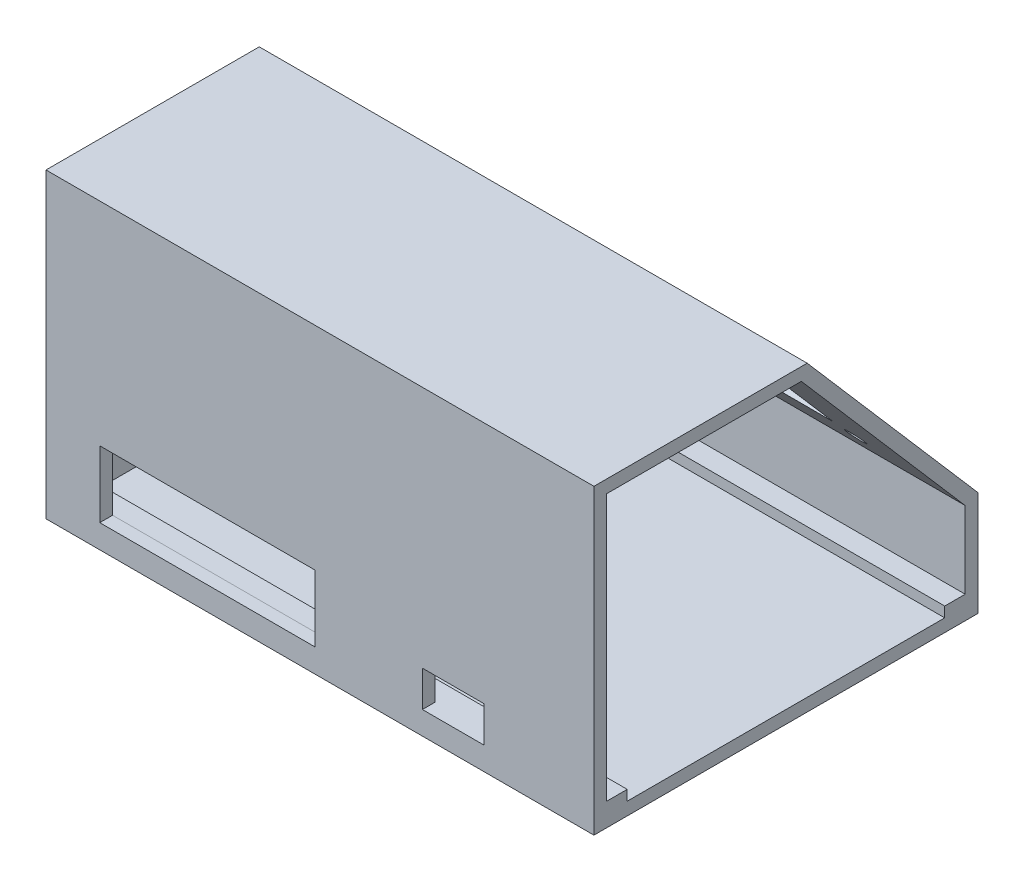
from build123d import *

# Parameters (mm, degrees)
BOSS_EXTRUDE2_DEPTH = 107
BOSS_EXTRUDE3_DEPTH = 107
CUT_EXTRUDE4_DEPTH  = 104.5
SKETCH4_W           = 4
SKETCH4_H           = 2
BOSS_EXTRUDE4_DEPTH = 104.5
SKETCH6_W           = 42
SKETCH6_H           = 13
CUT_EXTRUDE5_DEPTH  = 3
SKETCH7_W           = 12
SKETCH7_H           = 7
CUT_EXTRUDE6_DEPTH  = 3
SKETCH8_W           = 72
SKETCH8_H           = 26
CUT_EXTRUDE7_DEPTH  = 3
SKETCH9_R           = 1.85
CUT_EXTRUDE8_DEPTH  = 3


with BuildPart() as part:
    # Sketch1 → Boss-Extrude2 (new body)
    with BuildSketch(Plane(origin=(0, 0, 0), x_dir=(0, 0, -1), z_dir=(1, 0, 0))):
        Polygon((-70, 49.18258427), (-32, 49.18258427), (0, 12.18258427), (0, -4.81741573), (-70, -4.81741573), align=None)
    extrude(amount=BOSS_EXTRUDE2_DEPTH)

    # Sketch2 → Boss-Extrude3 (add)
    with BuildSketch(Plane(origin=(107, 0, 0), x_dir=(0, 0, -1), z_dir=(1, 0, 0))):
        Polygon((-72.5, -7.31741573), (-72.5, 51.68258427), (-30.856871673, 51.68258427), (2.5, 13.113701397), (2.5, -7.31741573), align=None)
        Polygon((-70, 49.18258427), (-32, 49.18258427), (0, 12.18258427), (0, -4.81741573), (-70, -4.81741573), align=None, mode=Mode.SUBTRACT)
    extrude(amount=-BOSS_EXTRUDE3_DEPTH)

    # Sketch3 → Cut-Extrude4 (cut)
    with BuildSketch(Plane(origin=(107, 0, 0), x_dir=(0, 0, -1), z_dir=(1, 0, 0))):
        Polygon((0, -4.81741573), (-70, -4.81741573), (-70, 49.18258427), (-32, 49.18258427), (0, 12.18258427), align=None)
    extrude(amount=-CUT_EXTRUDE4_DEPTH, mode=Mode.SUBTRACT)

    # Sketch4 → Boss-Extrude4 (add)
    with BuildSketch(Plane(origin=(2.5, 0, 0), x_dir=(0, 0, -1), z_dir=(1, 0, 0))):
        with Locations((-68, -3.81741573)):
            Rectangle(SKETCH4_W, SKETCH4_H)
        with Locations((-2, -3.81741573)):
            Rectangle(SKETCH4_W, SKETCH4_H)
    extrude(amount=BOSS_EXTRUDE4_DEPTH)

    # Sketch6 → Cut-Extrude5 (cut)
    with BuildSketch(Plane.XY.offset(72.5)):
        with Locations((31.5, 3.78258427)):
            Rectangle(SKETCH6_W, SKETCH6_H)
    extrude(amount=-CUT_EXTRUDE5_DEPTH, mode=Mode.SUBTRACT)

    # Sketch7 → Cut-Extrude6 (cut)
    with BuildSketch(Plane.XY.offset(72.5)):
        with Locations((79.5, 0.68258427)):
            Rectangle(SKETCH7_W, SKETCH7_H)
    extrude(amount=-CUT_EXTRUDE6_DEPTH, mode=Mode.SUBTRACT)

    # Sketch8 → Cut-Extrude7 (cut)
    with BuildSketch(Plane(origin=(0, 6.848487351, -7.9185635), x_dir=(-1, 0, 0), z_dir=(0, 0.654151933, -0.756363172))):
        with Locations((-53.5, 34.775885648)):
            Rectangle(SKETCH8_W, SKETCH8_H)
    extrude(amount=-CUT_EXTRUDE7_DEPTH, mode=Mode.SUBTRACT)

    # Sketch9 → Cut-Extrude8 (cut)
    with BuildSketch(Plane(origin=(0, 6.848487351, -7.9185635), x_dir=(-1, 0, 0), z_dir=(0, 0.654151933, -0.756363172))):
        with Locations((-91.606829089, 51.125885648)):
            Circle(SKETCH9_R)
        with Locations((-15.406829089, 51.125885648)):
            Circle(SKETCH9_R)
        with Locations((-15.406829089, 18.425885648)):
            Circle(SKETCH9_R)
        with Locations((-91.606829089, 18.425885648)):
            Circle(SKETCH9_R)
    extrude(amount=-CUT_EXTRUDE8_DEPTH, mode=Mode.SUBTRACT)


solid = part.part
